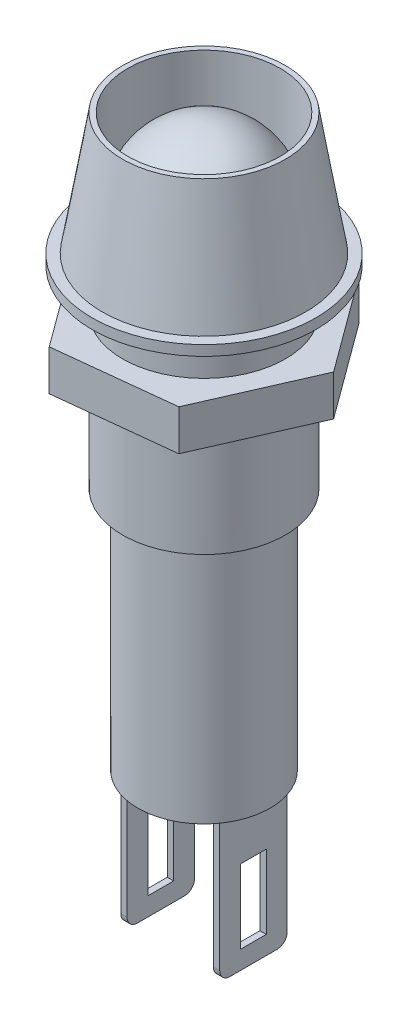
from build123d import *

# Parameters (mm, degrees)
SKETCH2_W           = 0.313326982
SKETCH2_H           = 3.317579804
BOSS_EXTRUDE1_DEPTH = 7
SKETCH3_W           = 1.255689372
SKETCH3_H           = 3.631317916
CUT_EXTRUDE1_DEPTH  = 8.932891857
FILLET1_R           = 0.5
BOSS_EXTRUDE2_START = 2
BOSS_EXTRUDE2_DEPTH = 2


with BuildPart() as part:
    # Sketch1 → Revolve1 (revolve)
    with BuildSketch(Plane(origin=(0, 0, 0), x_dir=(0, 1, 0), z_dir=(0, 0, 1))):
        Polygon((0, 0), (0, 3.25), (12, 3.25), (12, 4), (21.5, 4), (21.5, 5.5), (22, 5.5), (22, 5), (28, 4), (28, 3.75), (23, 3.75), (23, 3.5), (24, 3.5), (24, 0), align=None)
    revolve(axis=Axis((0, 0, 0), (0, -1, 0)))

    # Sketch2 → Boss-Extrude1 (add)
    with BuildSketch(Plane.XZ):
        with Locations((-2.276228366, 0)):
            Rectangle(SKETCH2_W, SKETCH2_H)
        with Locations((2.276228366, 0)):
            Rectangle(SKETCH2_W, SKETCH2_H)
    extrude(amount=BOSS_EXTRUDE1_DEPTH)

    # Sketch3 → Cut-Extrude1 (cut, through all)
    with BuildSketch(Plane.ZY.offset(2.432891857)):
        with Locations((0, -4.279803291)):
            Rectangle(SKETCH3_W, SKETCH3_H)
    extrude(amount=-CUT_EXTRUDE1_DEPTH, mode=Mode.SUBTRACT)

    # Fillet1
    fillet1_edges = [part.edges().sort_by_distance(p)[0] for p in [
        (-2.276228366, -7, -1.658789902),
        (-2.276228366, -7, 1.658789902),
        (2.276228366, -7, 1.658789902),
        (2.276228366, -7, -1.658789902),
    ]]
    fillet(fillet1_edges, radius=FILLET1_R)

    # Sketch4 → Boss-Extrude2 (add)
    with BuildSketch(Plane.XZ.offset(-21.5).offset(BOSS_EXTRUDE2_START)):
        Polygon((-2.321621061, 5.286152569), (-5.738752943, 0.632493468), (-3.417131883, -4.653659101), (2.321621061, -5.286152569), (5.738752943, -0.632493468), (3.417131883, 4.653659101), align=None)
    extrude(amount=BOSS_EXTRUDE2_DEPTH)


with BuildPart() as body_2:
    # Sketch6 → Green (revolve)
    with BuildSketch(Plane.XY):
        with BuildLine():
            Line((-3.5, 24), (0, 24))
            Line((0, 24), (0, 27.5))
            ThreePointArc((0, 27.5), (-2.474873734, 26.474873734), (-3.5, 24))
        make_face()
    revolve(axis=Axis((0, 24, 0), (0, 1, 0)))


solid = Compound([part.part, body_2.part])
